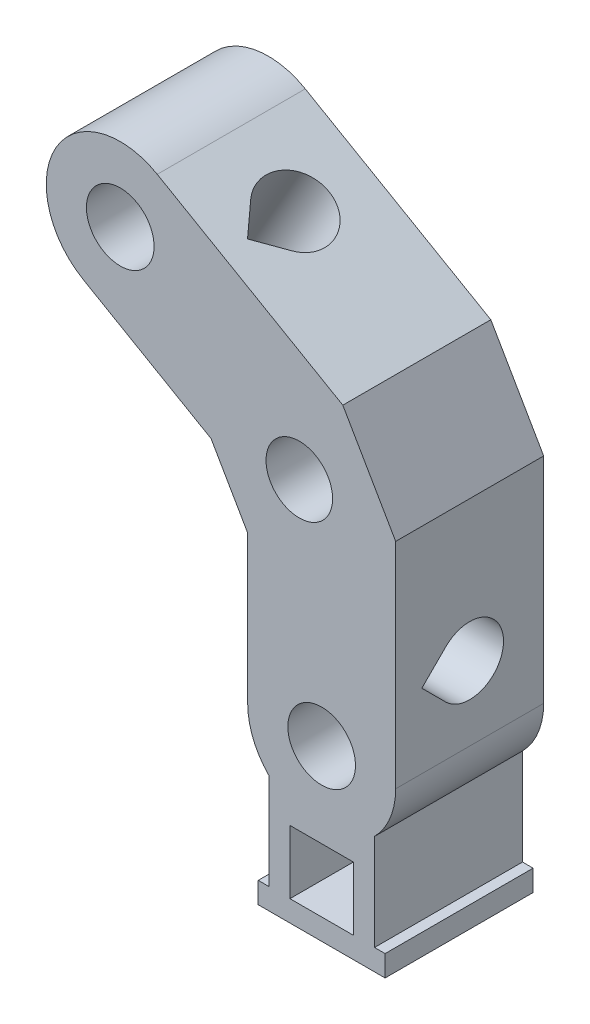
from build123d import *

# Parameters (mm, degrees)
SKETCH1_W           = 6
SKETCH1_H           = 6
BOSS_EXTRUDE1_DEPTH = 14
HOLE2_D             = 6.4
HOLE2_DEPTH         = 14
HOLE1_D             = 6.4
CUT_EXTRUDE2_DEPTH  = 15
CUT_EXTRUDE1_DEPTH  = 27.088457268
SKETCH8_R           = 3.15
CUT_EXTRUDE3_DEPTH  = 15


with BuildPart() as part:
    # Sketch1 → Boss-Extrude1 (new body)
    with BuildSketch(Plane.XY.offset(14)):
        with BuildLine():
            Line((7, 0), (7, 20.267949192))
            Line((7, 20.267949192), (2, 28.92820323))
            Line((2, 28.92820323), (-15.552558883, 39.062177826))
            ThreePointArc((-15.552558883, 39.062177826), (-25.11473671, 36.5), (-22.552558883, 26.937822174))
            Line((-22.552558883, 26.937822174), (-10.464101615, 19.958548116))
            Line((-10.464101615, 19.958548116), (-7, 13.958548116))
            Line((-7, 13.958548116), (-7, 0))
            ThreePointArc((-7, 0), (-6.480740698, -2.645751311), (-5, -4.898979486))
            Line((-5, -4.898979486), (-5, -14))
            Line((-5, -14), (-6, -14))
            Line((-6, -14), (-6, -16))
            Line((-6, -16), (6, -16))
            Line((6, -16), (6, -14))
            Line((6, -14), (5, -14))
            Line((5, -14), (5, -4.898979486))
            ThreePointArc((5, -4.898979486), (6.480740698, -2.645751311), (7, 0))
        make_face()
        with Locations((0, -11)):
            Rectangle(SKETCH1_W, SKETCH1_H, mode=Mode.SUBTRACT)
    extrude(amount=-BOSS_EXTRUDE1_DEPTH)

    # Hole2
    with Locations(Plane(origin=(0, 0, 0), x_dir=(-1, 0, 0), z_dir=(0, 0, -1))):
        with Locations((19.0525, 32.999898011)):
            Hole(HOLE2_D / 2, depth=HOLE2_DEPTH)

    # Hole1 (through all)
    with Locations(Plane(origin=(0, 0, 0), x_dir=(-1, 0, 0), z_dir=(0, 0, -1))):
        with Locations((0, 0)):
            Hole(HOLE1_D / 2)

    # Sketch3 → Cut-Extrude2 (cut, through all)
    with BuildSketch(Plane.ZY.offset(7)):
        with BuildLine():
            Line((9.2627417, 4.7372583), (11.5254834, 7))
            Line((11.5254834, 7), (9.2627417, 9.2627417))
            ThreePointArc((9.2627417, 9.2627417), (3.8, 7), (9.2627417, 4.7372583))
        make_face()
    extrude(amount=-CUT_EXTRUDE2_DEPTH, mode=Mode.SUBTRACT)

    # Sketch2 → Cut-Extrude1 (cut, through all)
    with BuildSketch(Plane(origin=(6.026279442, 10.437822174, 0), x_dir=(0.866025404, -0.5, 0), z_dir=(-0.5, -0.866025404, 0))):
        with BuildLine():
            Line((-25.999898011, 11.5254834), (-28.262639711, 9.2627417))
            ThreePointArc((-28.262639711, 9.2627417), (-25.999898011, 3.8), (-23.737156311, 9.2627417))
            Line((-23.737156311, 9.2627417), (-25.999898011, 11.5254834))
        make_face()
    extrude(amount=-CUT_EXTRUDE1_DEPTH, mode=Mode.SUBTRACT)

    # Sketch8 → Cut-Extrude3 (cut, through all)
    with BuildSketch(Plane.XY.offset(14)):
        with Locations((-2.116025404, 20.778312164)):
            Circle(SKETCH8_R)
    extrude(amount=-CUT_EXTRUDE3_DEPTH, mode=Mode.SUBTRACT)


solid = part.part
